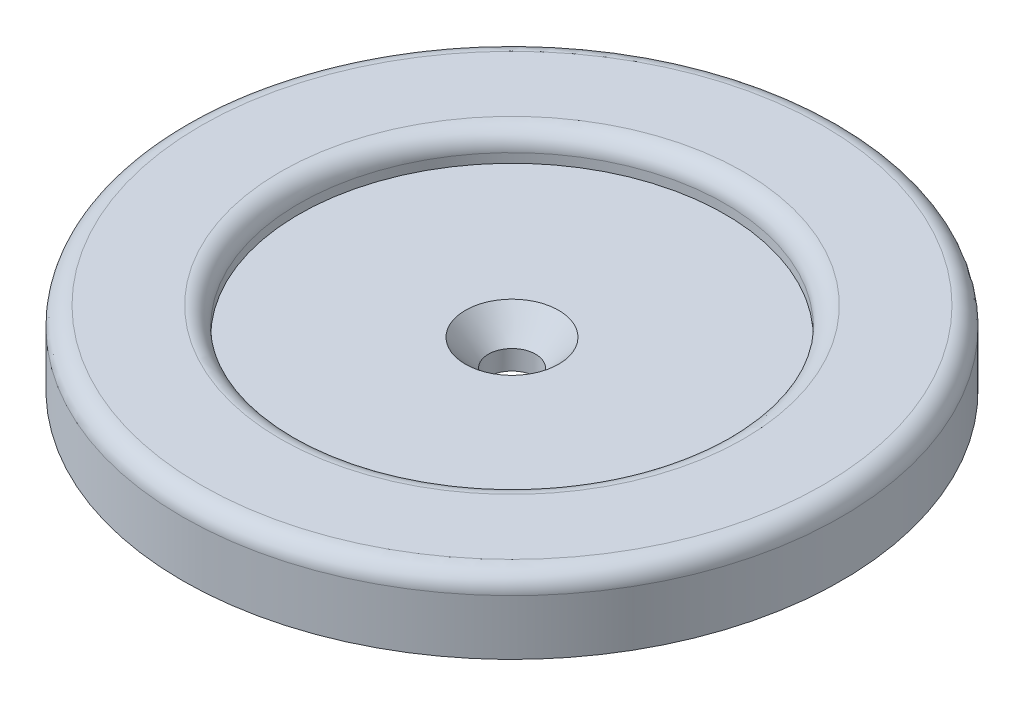
from build123d import *

# Parameters (mm, degrees)
SKETCH1_R                                        = 45.466
BOSS_EXTRUDE1_DEPTH                              = 25.4
CSK_FOR_1_4_FLAT_HEAD_MACHINE_SCREW1_D           = 6.5278
CSK_FOR_1_4_FLAT_HEAD_MACHINE_SCREW1_DEPTH       = 25.4
CSK_FOR_1_4_FLAT_HEAD_MACHINE_SCREW1_CSINK_D     = 12.8778
CSK_FOR_1_4_FLAT_HEAD_MACHINE_SCREW1_CSINK_ANGLE = 82
CSK_FOR_1_4_FLAT_HEAD_MACHINE_SCREW1_TIP         = 1.961148974
SKETCH9_R                                        = 53.031918303
CUT_EXTRUDE3_DEPTH                               = 12.7
SKETCH11_R                                       = 48.963999794
CUT_EXTRUDE4_DEPTH                               = 6.35
SKETCH13_R                                       = 45.466
SKETCH13_R_2                                     = 29.398178488
BOSS_EXTRUDE2_DEPTH                              = 3.81
SKETCH12_R                                       = 3.130864452
CUT_EXTRUDE5_DEPTH                               = 6.35
FILLET1_R                                        = 2.54


with BuildPart() as part:
    # Sketch1 → Boss-Extrude1 (new body)
    with BuildSketch(Plane(origin=(0, 0, 0), x_dir=(1, 0, 0), z_dir=(0, 1, 0))):
        Circle(SKETCH1_R)
    extrude(amount=BOSS_EXTRUDE1_DEPTH)

    # CSK for 1/4 Flat Head Machine Screw1
    with Locations(Plane(origin=(0, 25.4, 0), x_dir=(1, 0, 0), z_dir=(0, 1, 0))):
        with Locations((0, 0)):
            CounterSinkHole(CSK_FOR_1_4_FLAT_HEAD_MACHINE_SCREW1_D / 2, CSK_FOR_1_4_FLAT_HEAD_MACHINE_SCREW1_CSINK_D / 2, depth=CSK_FOR_1_4_FLAT_HEAD_MACHINE_SCREW1_DEPTH, counter_sink_angle=CSK_FOR_1_4_FLAT_HEAD_MACHINE_SCREW1_CSINK_ANGLE)
            with Locations((0, 0, -(CSK_FOR_1_4_FLAT_HEAD_MACHINE_SCREW1_DEPTH + CSK_FOR_1_4_FLAT_HEAD_MACHINE_SCREW1_TIP / 2))):  # 118° drill point
                Cone(0, CSK_FOR_1_4_FLAT_HEAD_MACHINE_SCREW1_D / 2, CSK_FOR_1_4_FLAT_HEAD_MACHINE_SCREW1_TIP, mode=Mode.SUBTRACT)

    # Sketch9 → Cut-Extrude3 (cut)
    with BuildSketch(Plane.XZ):
        Circle(SKETCH9_R)
    extrude(amount=-CUT_EXTRUDE3_DEPTH, mode=Mode.SUBTRACT)

    # Sketch11 → Cut-Extrude4 (cut)
    with BuildSketch(Plane.XZ.offset(-12.7)):
        Circle(SKETCH11_R)
    extrude(amount=-CUT_EXTRUDE4_DEPTH, mode=Mode.SUBTRACT)

    # Sketch13 → Boss-Extrude2 (add)
    with BuildSketch(Plane(origin=(0, 25.4, 0), x_dir=(1, 0, 0), z_dir=(0, 1, 0))):
        Circle(SKETCH13_R)
        Circle(SKETCH13_R_2, mode=Mode.SUBTRACT)
    extrude(amount=BOSS_EXTRUDE2_DEPTH)

    # Sketch12 → Cut-Extrude5 (cut)
    with BuildSketch(Plane.XZ.offset(-19.05)):
        with Locations((0, 38.309864452)):
            Circle(SKETCH12_R)
        with Locations((9.915322535, 37.004487476)):
            Circle(SKETCH12_R)
        with Locations((19.154932226, 33.177315831)):
            Circle(SKETCH12_R)
        with Locations((27.08916494, 27.08916494)):
            Circle(SKETCH12_R)
        with Locations((33.177315831, 19.154932226)):
            Circle(SKETCH12_R)
        with Locations((37.004487476, 9.915322535)):
            Circle(SKETCH12_R)
        with Locations((38.309864452, 0)):
            Circle(SKETCH12_R)
        with Locations((37.004487476, -9.915322535)):
            Circle(SKETCH12_R)
        with Locations((33.177315831, -19.154932226)):
            Circle(SKETCH12_R)
        with Locations((27.08916494, -27.08916494)):
            Circle(SKETCH12_R)
        with Locations((19.154932226, -33.177315831)):
            Circle(SKETCH12_R)
        with Locations((9.915322535, -37.004487476)):
            Circle(SKETCH12_R)
        with Locations((0, -38.309864452)):
            Circle(SKETCH12_R)
        with Locations((-9.915322535, -37.004487476)):
            Circle(SKETCH12_R)
        with Locations((-19.154932226, -33.177315831)):
            Circle(SKETCH12_R)
        with Locations((-27.08916494, -27.08916494)):
            Circle(SKETCH12_R)
        with Locations((-33.177315831, -19.154932226)):
            Circle(SKETCH12_R)
        with Locations((-37.004487476, -9.915322535)):
            Circle(SKETCH12_R)
        with Locations((-38.309864452, 0)):
            Circle(SKETCH12_R)
        with Locations((-37.004487476, 9.915322535)):
            Circle(SKETCH12_R)
        with Locations((-33.177315831, 19.154932226)):
            Circle(SKETCH12_R)
        with Locations((-27.08916494, 27.08916494)):
            Circle(SKETCH12_R)
        with Locations((-19.154932226, 33.177315831)):
            Circle(SKETCH12_R)
        with Locations((-9.915322535, 37.004487476)):
            Circle(SKETCH12_R)
    extrude(amount=-CUT_EXTRUDE5_DEPTH, mode=Mode.SUBTRACT)

    # Fillet1
    fillet1_edges = [part.edges().sort_by_distance(p)[0] for p in [
        (-45.466, 29.21, 0),
        (-29.398178488, 29.21, 0),
    ]]
    fillet(fillet1_edges, radius=FILLET1_R)


solid = part.part
